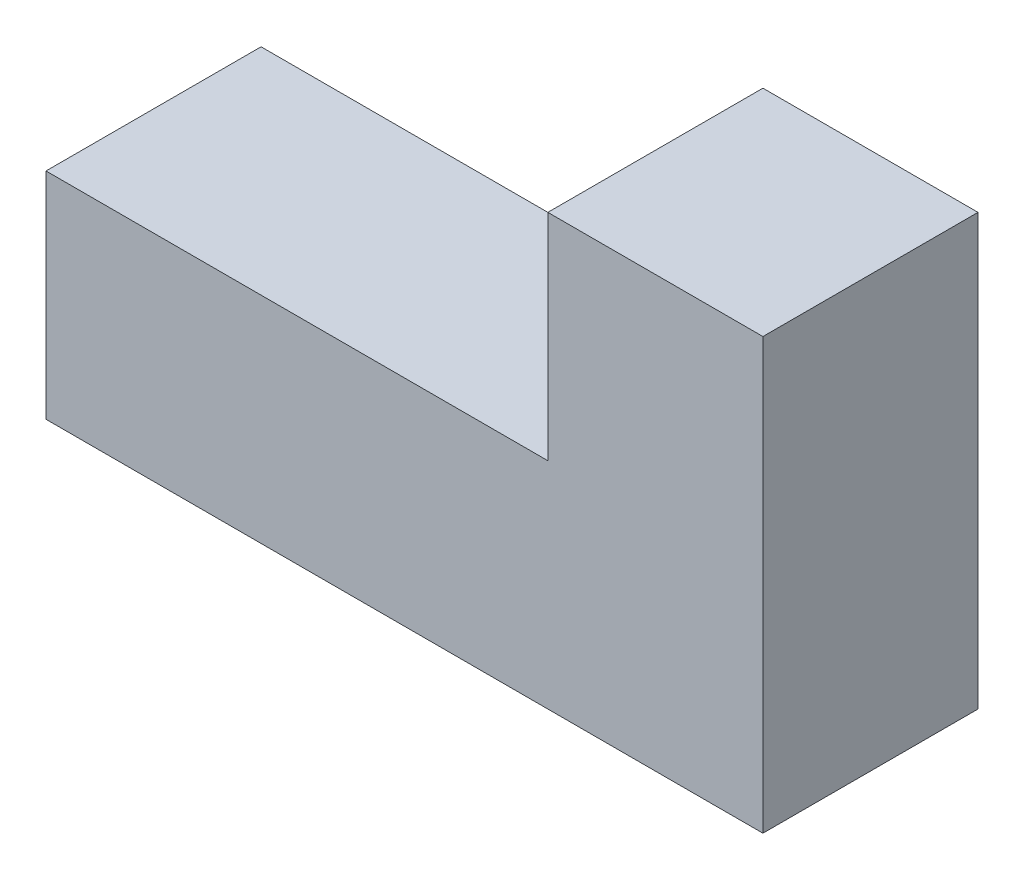
from build123d import *

# Parameters (mm, degrees)
EXTRUDE_1_DEPTH = 30


with BuildPart() as part:
    # Эскиз1 → Бобышка-Вытянуть1 (new body)
    with BuildSketch(Plane.XY):
        Polygon((0, 0), (100, 0), (100, 60), (70, 60), (70, 30), (0, 30), align=None)
    extrude(amount=EXTRUDE_1_DEPTH)


solid = part.part
